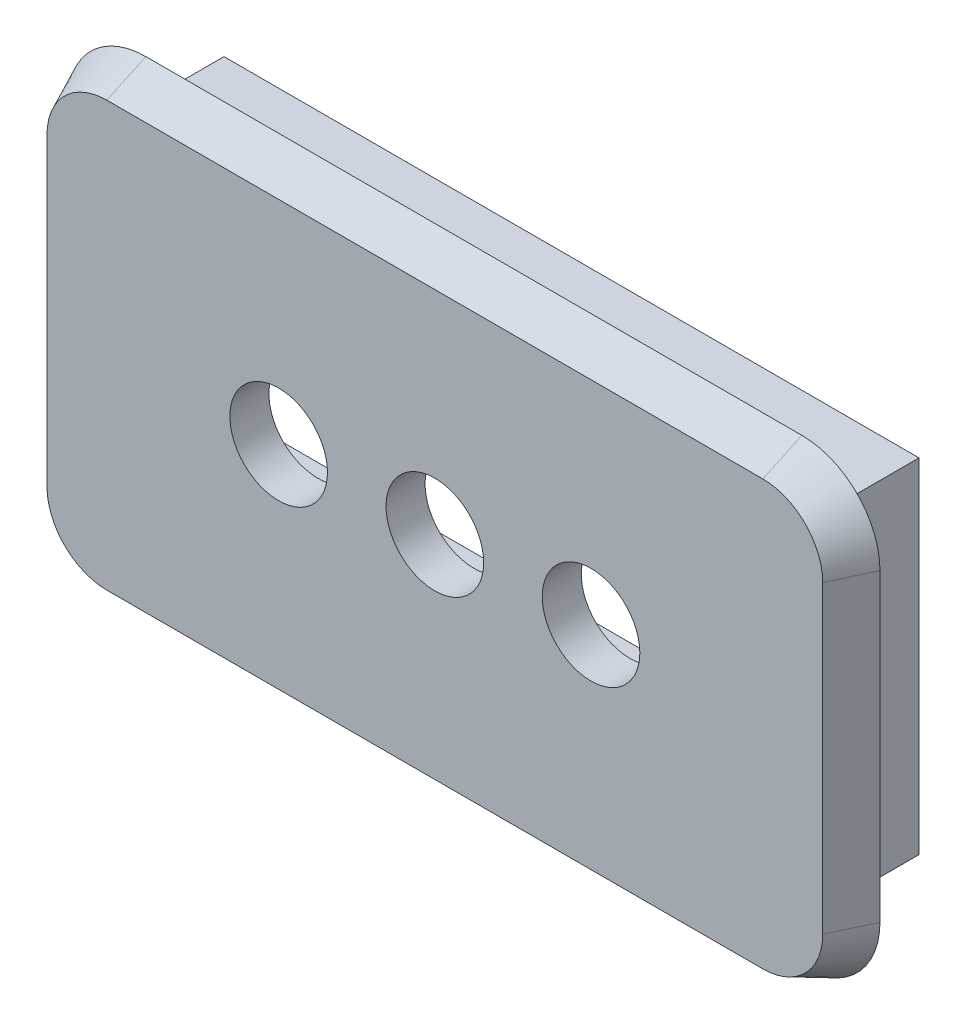
from build123d import *

# Parameters (mm, degrees)
SKETCH_1_W          = 17.8
SKETCH_1_H          = 8.8
SKETCH_1_W_2        = 15.8
SKETCH_1_H_2        = 6.8
EXTRUDE_1_DEPTH     = 2.5
EXTRUDE_2_DEPTH     = 1
EXTRUDE_2_TAPER     = 25
CUT_EXTRUDE_1_REACH = 5.5
SKETCH_3_R          = 1.25


with BuildPart() as part:
    # 草图1 → 凸台-拉伸1 (new body)
    with BuildSketch(Plane.XY):
        with Locations((0.435, 25.5)):
            Rectangle(SKETCH_1_W, SKETCH_1_H)
        with Locations((0.435, 25.5)):
            Rectangle(SKETCH_1_W_2, SKETCH_1_H_2, mode=Mode.SUBTRACT)
    extrude(amount=-EXTRUDE_1_DEPTH)

    # 草图2 → 凸台-拉伸2 (add)
    with BuildSketch(Plane.XY):
        with BuildLine():
            Line((10.835, 21.6), (10.835, 29.4))
            ThreePointArc((10.835, 29.4), (10.249213562, 30.814213562), (8.835, 31.4))
            Line((8.835, 31.4), (-7.965, 31.4))
            ThreePointArc((-7.965, 31.4), (-9.379213562, 30.814213562), (-9.965, 29.4))
            Line((-9.965, 29.4), (-9.965, 21.6))
            ThreePointArc((-9.965, 21.6), (-9.379213562, 20.185786438), (-7.965, 19.6))
            Line((-7.965, 19.6), (8.835, 19.6))
            ThreePointArc((8.835, 19.6), (10.249213562, 20.185786438), (10.835, 21.6))
        make_face()
    extrude(amount=EXTRUDE_2_DEPTH, taper=EXTRUDE_2_TAPER)

    # 草图3 → 切除-拉伸1 (cut, up to next)
    with BuildSketch(Plane.XY.offset(1), mode=Mode.PRIVATE) as cut_extrude_1_sk1:
        with Locations((0.435, 25.5)):
            Circle(SKETCH_3_R)
    cut_extrude_1_tool1 = extrude(cut_extrude_1_sk1.sketch, amount=-CUT_EXTRUDE_1_REACH, mode=Mode.PRIVATE) & part.part
    add(cut_extrude_1_tool1.solids().sort_by_distance((0.435, 25.5, 1))[0], mode=Mode.SUBTRACT)
    # 草图3 → 切除-拉伸1 (cut, up to next)
    with BuildSketch(Plane.XY.offset(1), mode=Mode.PRIVATE) as cut_extrude_1_sk2:
        with Locations((-3.565, 25.5)):
            Circle(SKETCH_3_R)
    cut_extrude_1_tool2 = extrude(cut_extrude_1_sk2.sketch, amount=-CUT_EXTRUDE_1_REACH, mode=Mode.PRIVATE) & part.part
    add(cut_extrude_1_tool2.solids().sort_by_distance((-3.565, 25.5, 1))[0], mode=Mode.SUBTRACT)
    # 草图3 → 切除-拉伸1 (cut, up to next)
    with BuildSketch(Plane.XY.offset(1), mode=Mode.PRIVATE) as cut_extrude_1_sk3:
        with Locations((4.435, 25.5)):
            Circle(SKETCH_3_R)
    cut_extrude_1_tool3 = extrude(cut_extrude_1_sk3.sketch, amount=-CUT_EXTRUDE_1_REACH, mode=Mode.PRIVATE) & part.part
    add(cut_extrude_1_tool3.solids().sort_by_distance((4.435, 25.5, 1))[0], mode=Mode.SUBTRACT)


solid = part.part
